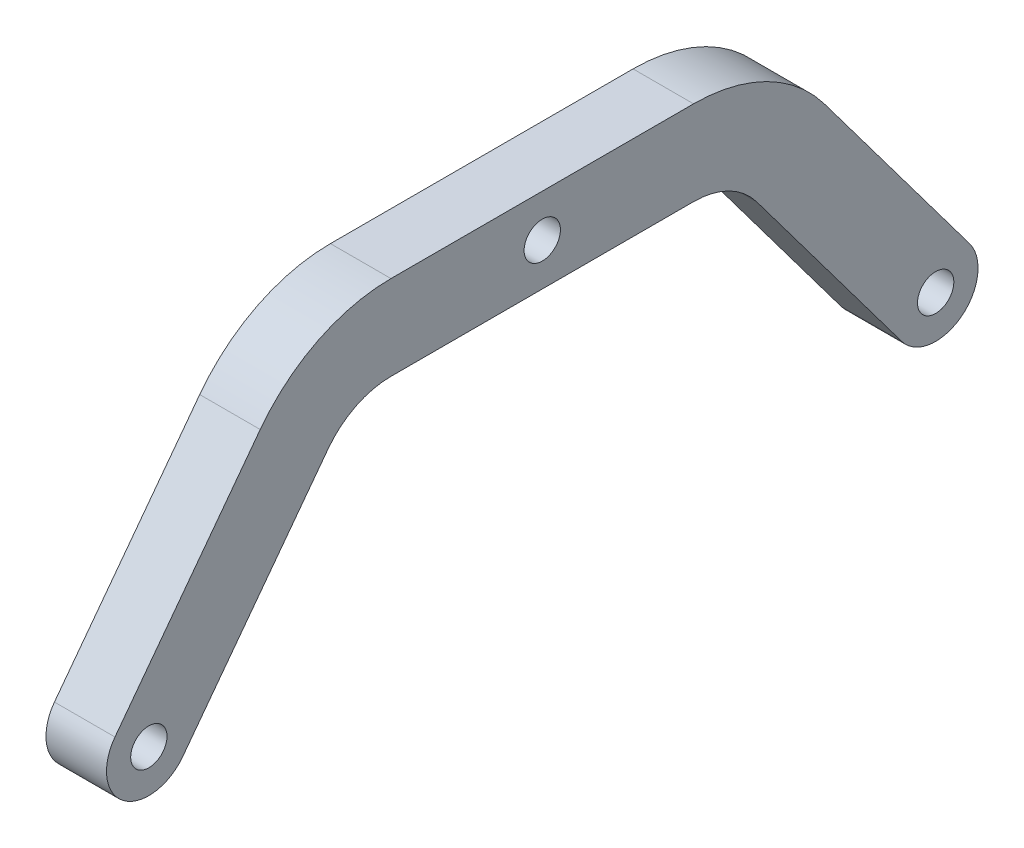
from build123d import *

# Parameters (mm, degrees)
SKETCH1_R           = 1.5
BOSS_EXTRUDE1_DEPTH = 2.5


with BuildPart() as part:
    # Sketch1 → Boss-Extrude1 (new body, symmetric)
    with BuildSketch(Plane(origin=(0, 0, 0), x_dir=(0, 0, -1), z_dir=(1, 0, 0))):
        with BuildLine():
            Line((23.3, 18.1), (35.3, 2.1))
            ThreePointArc((35.3, 2.1), (34.6, -2.8), (29.7, -2.1))
            Line((29.7, -2.1), (17.7, 13.9))
            ThreePointArc((17.7, 13.9), (15.406888371, 15.813776741), (12.5, 16.5))
            Line((12.5, 16.5), (-12.5, 16.5))
            ThreePointArc((-12.5, 16.5), (-15.406888371, 15.813776741), (-17.7, 13.9))
            Line((-17.7, 13.9), (-29.7, -2.1))
            ThreePointArc((-29.7, -2.1), (-34.6, -2.8), (-35.3, 2.1))
            Line((-35.3, 2.1), (-23.3, 18.1))
            ThreePointArc((-23.3, 18.1), (-18.537383539, 22.074767078), (-12.5, 23.5))
            Line((-12.5, 23.5), (12.5, 23.5))
            ThreePointArc((12.5, 23.5), (18.537383539, 22.074767078), (23.3, 18.1))
        make_face()
        with Locations((-32.5, 0)):
            Circle(SKETCH1_R, mode=Mode.SUBTRACT)
        with Locations((32.5, 0)):
            Circle(SKETCH1_R, mode=Mode.SUBTRACT)
        with Locations((0, 20)):
            Circle(SKETCH1_R, mode=Mode.SUBTRACT)
    extrude(amount=BOSS_EXTRUDE1_DEPTH, both=True)


solid = part.part
